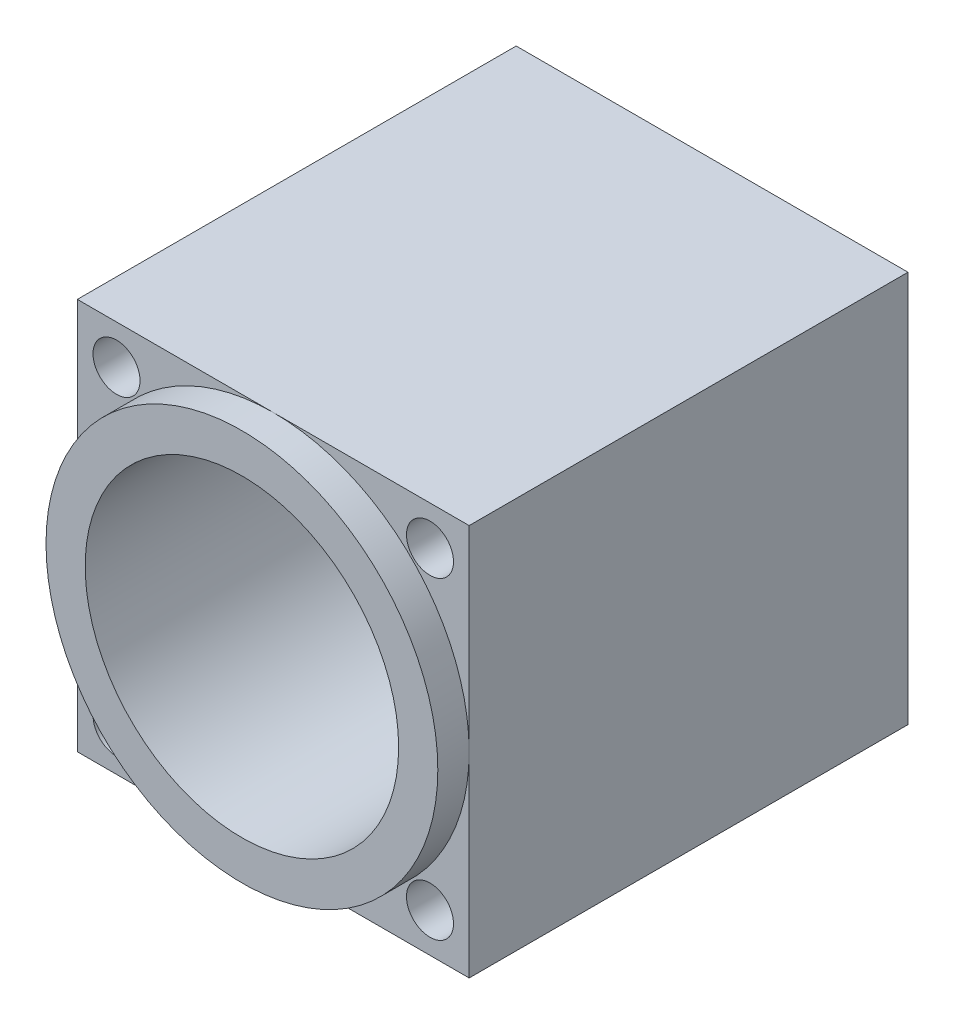
from build123d import *

# Parameters (mm, degrees)
ESQUISSE1_W      = 25
ESQUISSE1_H      = 25
ESQUISSE1_R      = 1.5
ESQUISSE1_R_2    = 3
EXTRUSION3_DEPTH = 30
ESQUISSE8_R      = 10
EXTRUSION4_DEPTH = 28
ESQUISSE10_R     = 18.049415766
ESQUISSE10_R_2   = 12.5
EXTRUSION6_DEPTH = 2


with BuildPart() as part:
    # Esquisse1 → Extrusion3 (new body)
    with BuildSketch(Plane.XY):
        Rectangle(ESQUISSE1_W, ESQUISSE1_H)
        with Locations((10, 10)):
            Circle(ESQUISSE1_R, mode=Mode.SUBTRACT)
        Circle(ESQUISSE1_R_2, mode=Mode.SUBTRACT)
        with Locations((-10, 10)):
            Circle(ESQUISSE1_R, mode=Mode.SUBTRACT)
        with Locations((10, -10)):
            Circle(ESQUISSE1_R, mode=Mode.SUBTRACT)
        with Locations((-10, -10)):
            Circle(ESQUISSE1_R, mode=Mode.SUBTRACT)
    extrude(amount=EXTRUSION3_DEPTH)

    # Esquisse8 → Extrusion4 (cut)
    with BuildSketch(Plane.XY.offset(30)):
        Circle(ESQUISSE8_R)
    extrude(amount=-EXTRUSION4_DEPTH, mode=Mode.SUBTRACT)

    # Esquisse10 → Extrusion6 (cut)
    with BuildSketch(Plane.XY.offset(30)):
        Circle(ESQUISSE10_R)
        Circle(ESQUISSE10_R_2, mode=Mode.SUBTRACT)
    extrude(amount=-EXTRUSION6_DEPTH, mode=Mode.SUBTRACT)


solid = part.part
